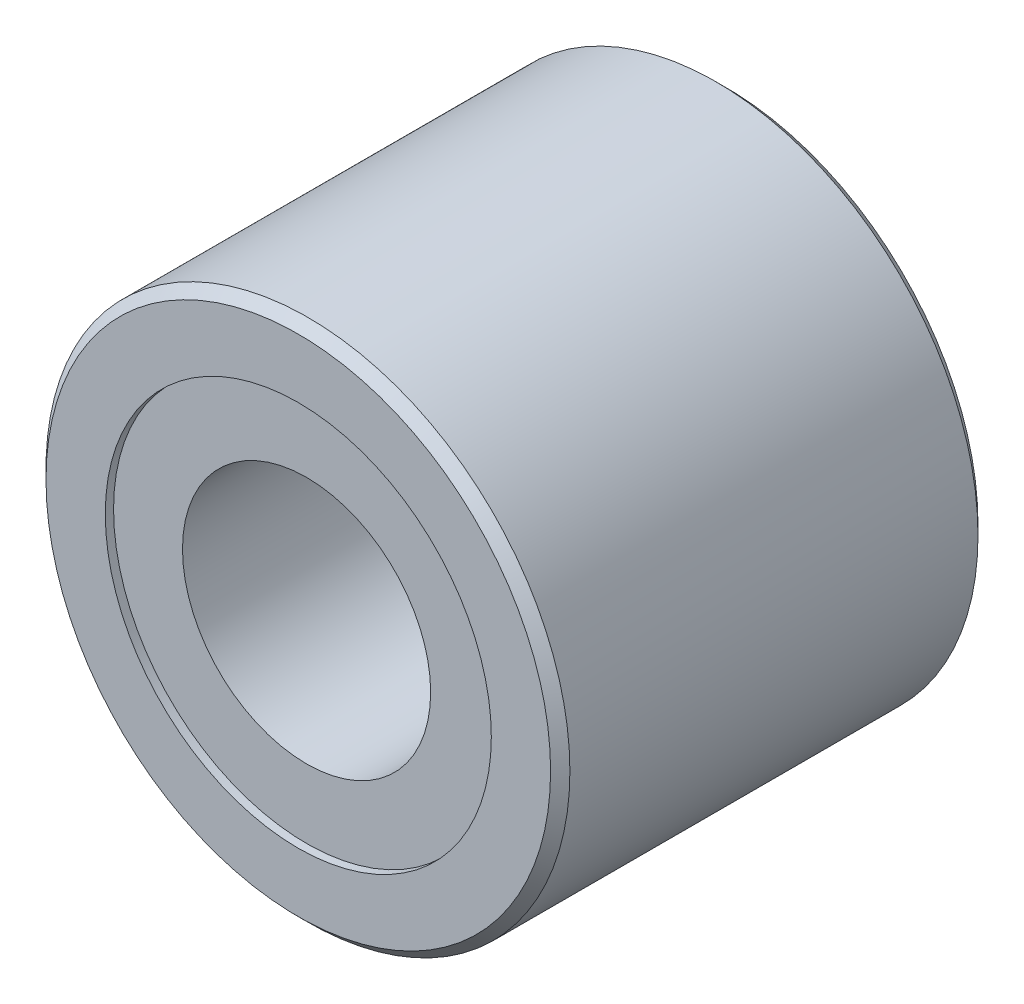
from build123d import *

# Parameters (mm, degrees)
SCHIZZO1_R                   = 9.5
SCHIZZO1_R_2                 = 7
ESTRUSIONE_ESTRUSIONE2_DEPTH = 15.5
SCHIZZO2_R                   = 7
SCHIZZO2_R_2                 = 4.5
ESTRUSIONE_ESTRUSIONE3_DEPTH = 14.9
SMUSSO1_SIZE                 = 0.35


with BuildPart() as part:
    # Schizzo1 → Estrusione-Estrusione2 (new body)
    with BuildSketch(Plane.XY):
        Circle(SCHIZZO1_R)
        Circle(SCHIZZO1_R_2, mode=Mode.SUBTRACT)
    extrude(amount=ESTRUSIONE_ESTRUSIONE2_DEPTH)

    # Schizzo2 → Estrusione-Estrusione3 (add)
    with BuildSketch(Plane(origin=(0, 0, 0.3), x_dir=(-1, 0, 0), z_dir=(0, 0, -1))):
        Circle(SCHIZZO2_R)
        Circle(SCHIZZO2_R_2, mode=Mode.SUBTRACT)
    extrude(amount=-ESTRUSIONE_ESTRUSIONE3_DEPTH)

    # Smusso1
    smusso1_edges = [part.edges().sort_by_distance(p)[0] for p in [
        (-9.5, 0, 0),
        (-9.5, 0, 15.5),
    ]]
    chamfer(smusso1_edges, length=SMUSSO1_SIZE)


solid = part.part
